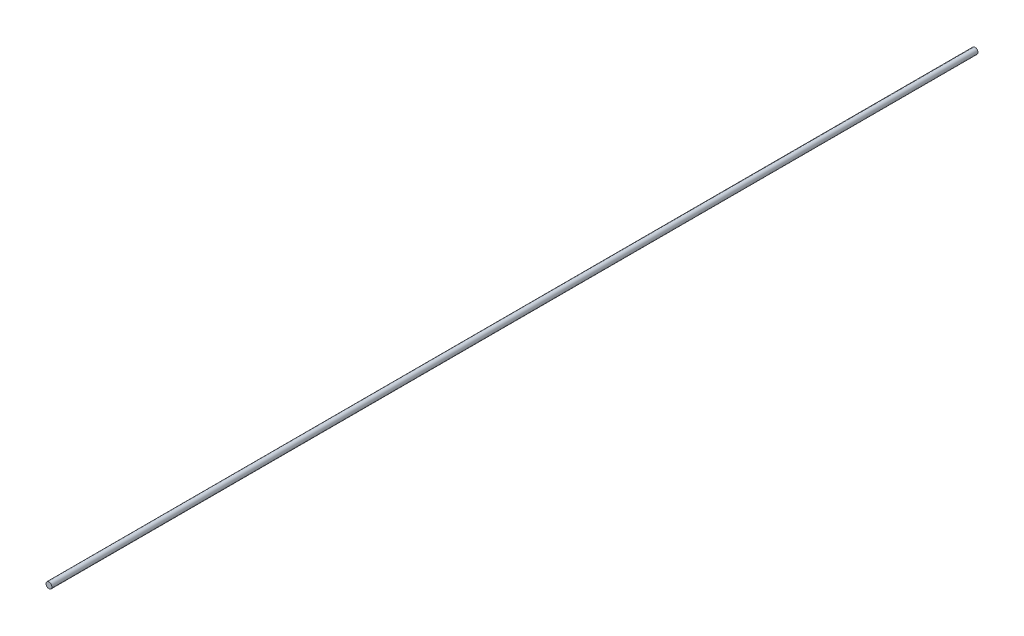
from build123d import *

# Parameters (mm, degrees)
SKETCH1_R           = 8
BOSS_EXTRUDE1_DEPTH = 2500


with BuildPart() as part:
    # Sketch1 → Boss-Extrude1 (new body)
    with BuildSketch(Plane.XY):
        Circle(SKETCH1_R)
    extrude(amount=BOSS_EXTRUDE1_DEPTH)


solid = part.part
